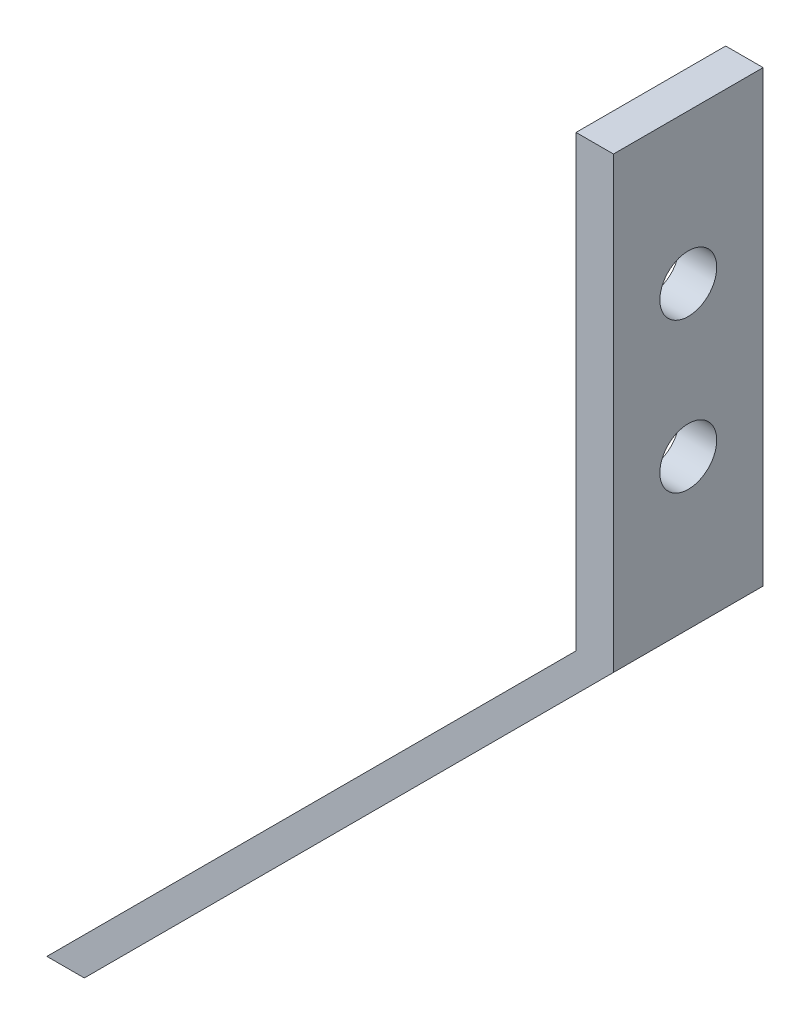
from build123d import *

# Parameters (mm, degrees)
SKETCH1_W           = 6.35
SKETCH1_H           = 76.2
BOSS_EXTRUDE1_DEPTH = 25.4
SKETCH2_R           = 4.826
CUT_EXTRUDE1_DEPTH  = 25.4


with BuildPart() as part:
    # Sketch1 → Boss-Extrude1 (new body)
    with BuildSketch(Plane.XY):
        with Locations((0, 38.1)):
            Rectangle(SKETCH1_W, SKETCH1_H)
        Polygon((-92.977561211, -89.802561211), (-86.627561211, -89.802561211), (3.175, 0), (-3.175, 0), align=None)
    extrude(amount=BOSS_EXTRUDE1_DEPTH)

    # Sketch2 → Cut-Extrude1 (cut)
    with BuildSketch(Plane.ZY.offset(3.175)):
        with Locations((12.7, 50.8)):
            Circle(SKETCH2_R)
        with Locations((12.7, 25.4)):
            Circle(SKETCH2_R)
    extrude(amount=-CUT_EXTRUDE1_DEPTH, mode=Mode.SUBTRACT)


solid = part.part
